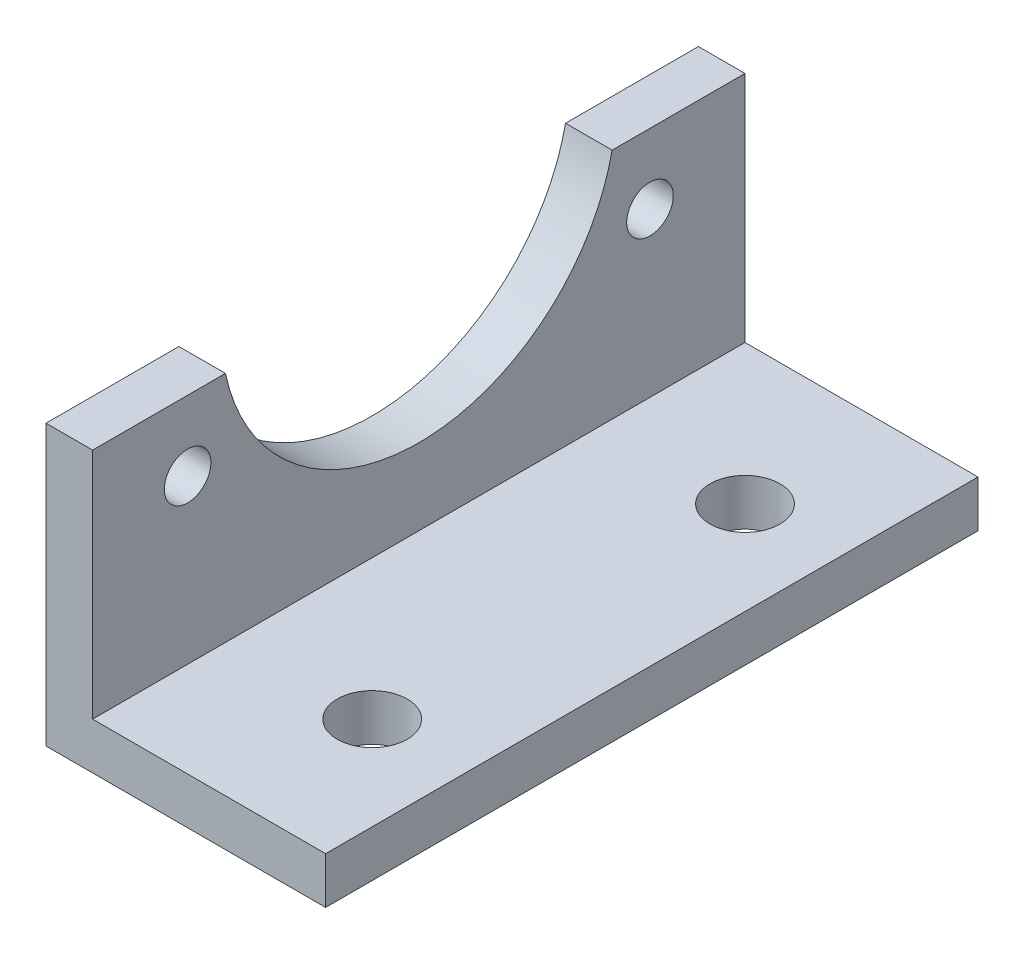
from build123d import *

# Parameters (mm, degrees)
BOSS_EXTRUDE1_DEPTH = 88.9
SKETCH2_R           = 3.175
CUT_EXTRUDE1_DEPTH  = 76.2
SKETCH3_R           = 4.7625
CUT_EXTRUDE2_DEPTH  = 39.1


with BuildPart() as part:
    # Sketch1 → Boss-Extrude1 (new body)
    with BuildSketch(Plane.XY):
        Polygon((0, 0), (0, 38.1), (6.35, 38.1), (6.35, 6.35), (38.1, 6.35), (38.1, 0), align=None)
    extrude(amount=BOSS_EXTRUDE1_DEPTH)

    # Sketch2 → Cut-Extrude1 (cut)
    with BuildSketch(Plane.ZY):
        with Locations((12.95, 28.575)):
            Circle(SKETCH2_R)
        with Locations((75.95, 28.575)):
            Circle(SKETCH2_R)
        with BuildLine():
            ThreePointArc((18.104961724, 38.1), (44.45, 16.733289595), (70.795038276, 38.1))
            Line((70.795038276, 38.1), (18.104961724, 38.1))
        make_face()
    extrude(amount=-CUT_EXTRUDE1_DEPTH, mode=Mode.SUBTRACT)

    # Sketch3 → Cut-Extrude2 (cut, through all)
    with BuildSketch(Plane.XZ):
        with Locations((25.4, 69.85)):
            Circle(SKETCH3_R)
        with Locations((25.4, 19.05)):
            Circle(SKETCH3_R)
    extrude(amount=-CUT_EXTRUDE2_DEPTH, mode=Mode.SUBTRACT)


solid = part.part
